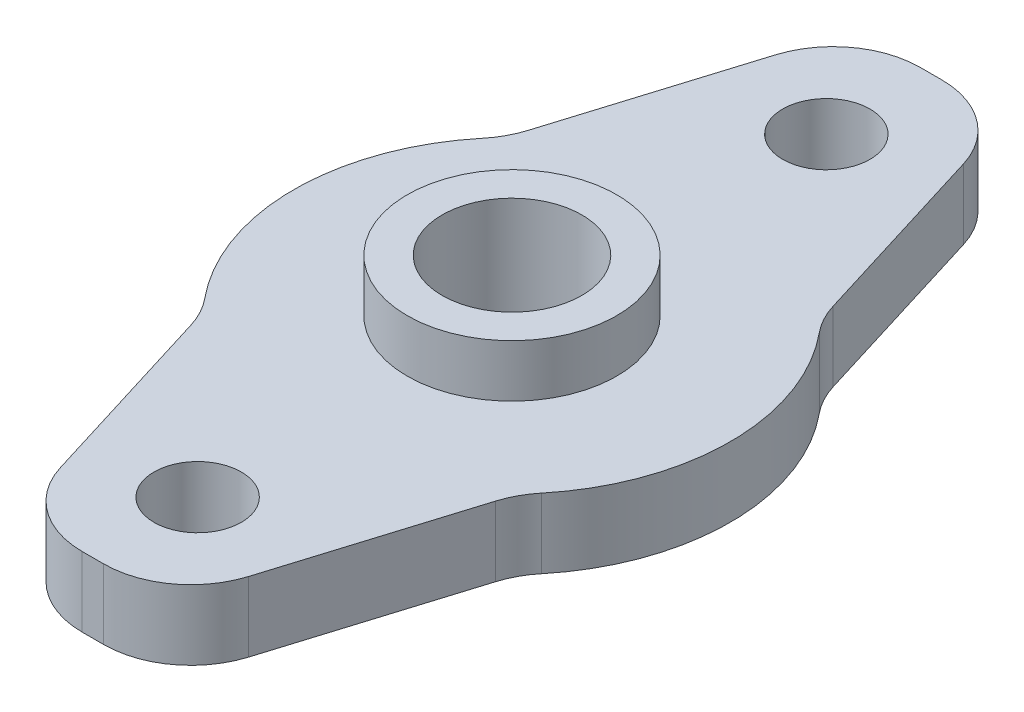
from build123d import *

# Parameters (mm, degrees)
SKETCH_1_R      = 2.5
SKETCH_1_R_2    = 12.5
SKETCH_1_R_3    = 4
EXTRUDE_1_DEPTH = 4
FILLET_1_R      = 5
SKETCH_2_R      = 6
SKETCH_2_R_2    = 4
EXTRUDE_2_DEPTH = 3


with BuildPart() as part:
    # 草图1 → 凸台-拉伸1 (new body)
    with BuildSketch(Plane(origin=(0, 0, 0), x_dir=(1, 0, 0), z_dir=(0, 1, 0))):
        with BuildLine():
            Line((-9.042322889, -8.630550201), (-4.305971765, -24))
            Line((-4.305971765, -24), (4.305971765, -24))
            Line((4.305971765, -24), (9.042322889, -8.630550201))
            ThreePointArc((9.042322889, -8.630550201), (0, -12.5), (-9.042322889, -8.630550201))
        make_face()
        with Locations((0, -18)):
            Circle(SKETCH_1_R, mode=Mode.SUBTRACT)
        Circle(SKETCH_1_R_2)
        Circle(SKETCH_1_R_3, mode=Mode.SUBTRACT)
        with BuildLine():
            Line((-4.305971765, 24), (-9.042322889, 8.630550201))
            ThreePointArc((-9.042322889, 8.630550201), (0, 12.5), (9.042322889, 8.630550201))
            Line((9.042322889, 8.630550201), (4.305971765, 24))
            Line((4.305971765, 24), (-4.305971765, 24))
        make_face()
        with Locations((0, 18)):
            Circle(SKETCH_1_R, mode=Mode.SUBTRACT)
    extrude(amount=EXTRUDE_1_DEPTH)

    # 圆角1
    fillet_1_edges = [part.edges().sort_by_distance(p)[0] for p in [
        (4.305971765, 2, 24),
        (-4.305971765, 2, 24),
        (-9.042322889, 2, 8.630550201),
        (-9.042322889, 2, -8.630550201),
        (-4.305971765, 2, -24),
        (4.305971765, 2, -24),
        (9.042322889, 2, -8.630550201),
        (9.042322889, 2, 8.630550201),
    ]]
    fillet(fillet_1_edges, radius=FILLET_1_R)

    # 草图2 → 凸台-拉伸2 (add)
    with BuildSketch(Plane(origin=(0, 4, 0), x_dir=(1, 0, 0), z_dir=(0, 1, 0))):
        Circle(SKETCH_2_R)
        Circle(SKETCH_2_R_2, mode=Mode.SUBTRACT)
    extrude(amount=EXTRUDE_2_DEPTH)


solid = part.part
